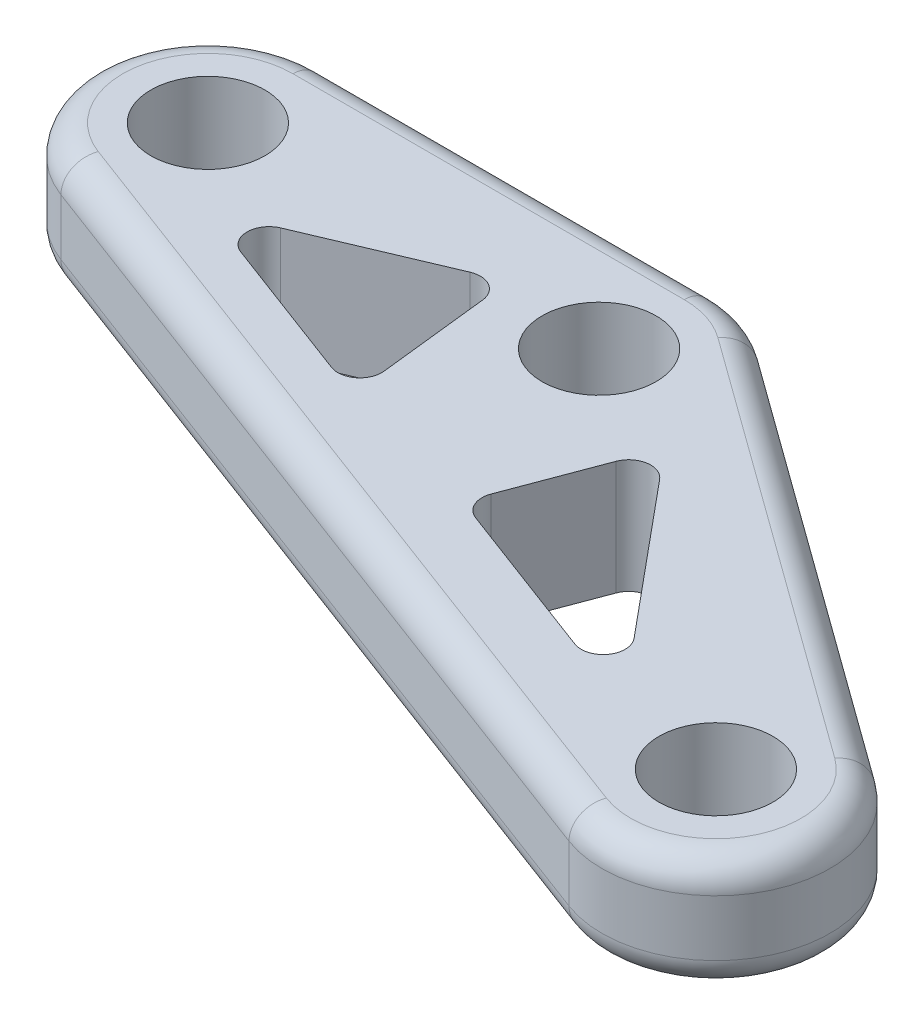
from build123d import *

# Parameters (mm, degrees)
SKETCH1_R           = 5
BOSS_EXTRUDE1_DEPTH = 10
FILLET1_R           = 2.54
SCALE1_SCALE        = 0.66
FILLET2_R           = 1.27


with BuildPart() as part:
    # Sketch1 → Boss-Extrude1 (new body)
    with BuildSketch(Plane(origin=(0, 0, 0), x_dir=(1, 0, 0), z_dir=(0, 1, 0))):
        with BuildLine():
            Line((-37.807044038, -9.361111111), (33.524622629, -36.160986681))
            ThreePointArc((33.524622629, -36.160986681), (45.851500304, -31.531347991), (42.90340673, -18.698023718))
            Line((42.90340673, -18.698023718), (5.861740063, 8.101851852))
            ThreePointArc((5.861740063, 8.101851852), (3.080704585, 9.513635439), (0, 10))
            Line((0, 10), (-34.29, 10))
            ThreePointArc((-34.29, 10), (-44.128981429, 1.787300882), (-37.807044038, -9.361111111))
        make_face()
        with Locations((-34.29, 0)):
            Circle(SKETCH1_R, mode=Mode.SUBTRACT)
        Circle(SKETCH1_R, mode=Mode.SUBTRACT)
        with Locations((37.041666667, -26.79987557)):
            Circle(SKETCH1_R, mode=Mode.SUBTRACT)
        Polygon((-7.373318213, -14.24424589), (-27.557795825, -6.660776812), (-9.089196081, 1.165091942), align=None, mode=Mode.SUBTRACT)
        Polygon((10.448030186, -4.7063742), (5.617045705, -17.564724), (28.147439019, -26.029572301), align=None, mode=Mode.SUBTRACT)
    extrude(amount=BOSS_EXTRUDE1_DEPTH)

    # Fillet1
    fillet1_edges = [part.edges().sort_by_distance(p)[0] for p in [
        (45.851500304, 10, 31.531347991),
        (24.382573397, 10, 5.298085933),
        (3.080704585, 10, -9.513635439),
        (-17.145, 10, -10),
        (-44.128981429, 10, -1.787300882),
        (-17.145, 0, -10),
        (3.080704585, 0, -9.513635439),
        (24.382573397, 0, 5.298085933),
        (-2.141210705, 10, 22.761048896),
        (45.851500304, 0, 31.531347991),
        (-2.141210705, 0, 22.761048896),
        (-44.128981429, 0, -1.787300882),
    ]]
    fillet(fillet1_edges, radius=FILLET1_R)


with BuildPart() as part_1:
    # Scale1: scaled about (2.327239798, 5, 10.366216283)
    add(part.part.scale(SCALE1_SCALE).moved(Location((0.791261531, 1.7, 3.524513536))))

    # Fillet2
    fillet2_edges = [part_1.edges().sort_by_distance(p)[0] for p in [
        (-4.075128489, 5, 12.925715824),
        (-5.207607882, 5, 2.755552855),
        (-17.396883713, 5, 7.920626232),
        (19.368571284, 5, 20.704031255),
        (7.686961454, 5, 6.630720508),
        (4.498511697, 5, 15.117231376),
    ]]
    fillet(fillet2_edges, radius=FILLET2_R)


solid = part_1.part
